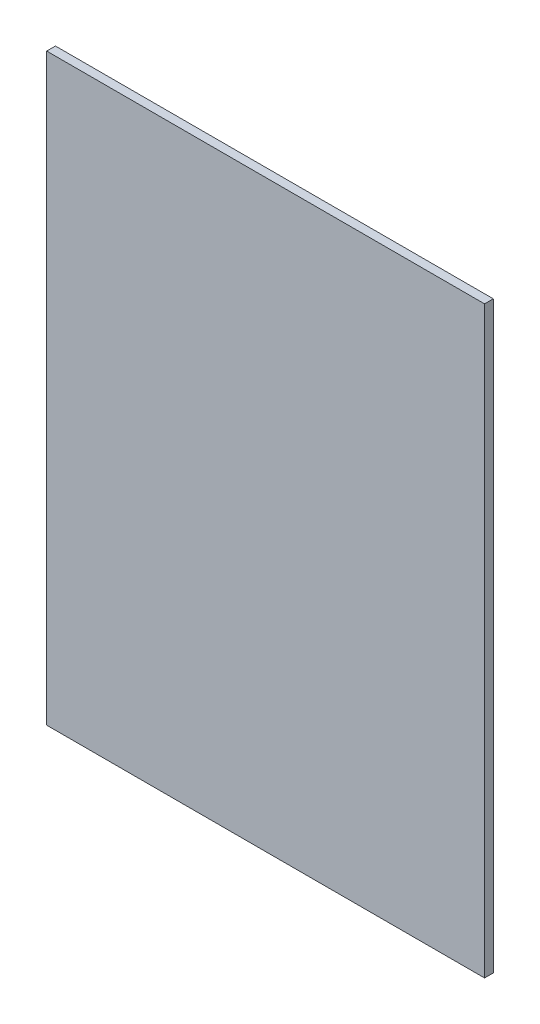
from build123d import *

# Parameters (mm, degrees)
SCHIZZO1_W                   = 150
SCHIZZO1_H                   = 200
ESTRUSIONE_ESTRUSIONE1_DEPTH = 3


with BuildPart() as part:
    # Schizzo1 → Estrusione-Estrusione1 (new body)
    with BuildSketch(Plane.XY):
        Rectangle(SCHIZZO1_W, SCHIZZO1_H)
    extrude(amount=ESTRUSIONE_ESTRUSIONE1_DEPTH)


solid = part.part
